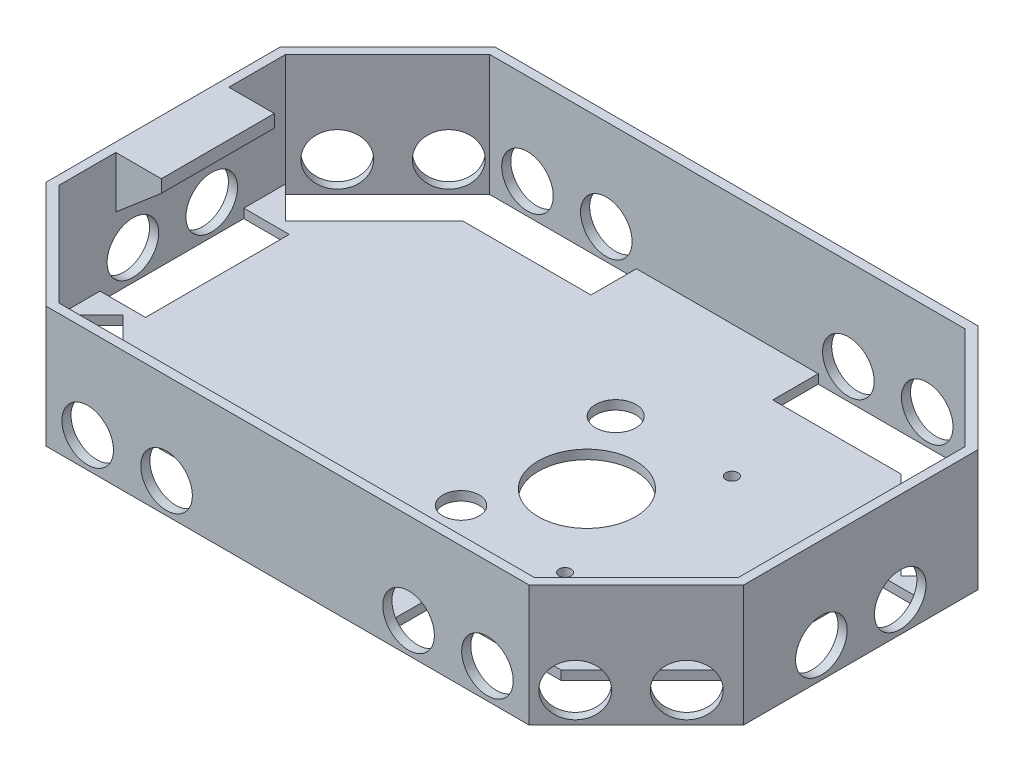
from build123d import *

# Parameters (mm, degrees)
SKETCH2_W               = 230
SKETCH2_H               = 148
BOSS_EXTRUDE1_DEPTH     = 40
CUT_EXTRUDE2_DEPTH      = 126
SHELL2_T                = -3
SKETCH6_R               = 16
SKETCH6_R_2             = 6
SKETCH6_R_3             = 2
SKETCH6_R_4             = 6.65813103
SKETCH6_R_5             = 2.01097319
CUT_EXTRUDE3_DEPTH      = 126
SKETCH8_W               = 15
SKETCH8_H               = 47.399828673
CUT_EXTRUDE4_DEPTH      = 10
SKETCH12_R              = 8.5
CUT_EXTRUDE7_DEPTH      = 4
CUT_EXTRUDE7_DEPTH_BACK = 13
SKETCH13_R              = 8.5
CUT_EXTRUDE8_DEPTH      = 10
SKETCH14_R              = 8.5
CUT_EXTRUDE9_DEPTH      = 10
SKETCH15_R              = 8.5
CUT_EXTRUDE10_DEPTH     = 10
SKETCH16_R              = 8.5
CUT_EXTRUDE11_DEPTH     = 10
SKETCH17_R              = 8.5
CUT_EXTRUDE12_DEPTH     = 10
SKETCH18_R              = 8.5
CUT_EXTRUDE13_DEPTH     = 10
SKETCH19_R              = 8.5
CUT_EXTRUDE14_DEPTH     = 10
SKETCH23_W              = 37.252555384
SKETCH23_H              = 4.191255607
BOSS_EXTRUDE2_DEPTH     = 15
BOSS_EXTRUDE3_DEPTH     = 37.252555


with BuildPart() as part:
    # Sketch2 → Boss-Extrude1 (new body)
    with BuildSketch(Plane(origin=(0, 0, 0), x_dir=(1, 0, 0), z_dir=(0, 1, 0))):
        Rectangle(SKETCH2_W, SKETCH2_H)
    extrude(amount=BOSS_EXTRUDE1_DEPTH)

    # Sketch4 → Cut-Extrude2 (cut)
    with BuildSketch(Plane(origin=(0, 40, 0), x_dir=(1, 0, 0), z_dir=(0, 1, 0))):
        Polygon((-79.644660941, 74), (-115, 38.644660941), (-115, 74), align=None)
        Polygon((115, 74), (79.644660941, 74), (115, 38.644660941), align=None)
        Polygon((115, -38.644660941), (115, -74), (79.644660941, -74), align=None)
        Polygon((-115, -74), (-79.644660941, -74), (-115, -38.644660941), align=None)
    extrude(amount=-CUT_EXTRUDE2_DEPTH, mode=Mode.SUBTRACT)

    # Shell2
    shell2_openings = [part.faces().sort_by_distance(p)[0] for p in [
        (0, 40, 0),
    ]]
    offset(amount=SHELL2_T, openings=shell2_openings, kind=Kind.INTERSECTION)

    # Sketch6 → Cut-Extrude3 (cut)
    with BuildSketch(Plane.XZ):
        with Locations((24.697986577, 0)):
            Circle(SKETCH6_R)
        with Locations((8.697986577, 25.5)):
            Circle(SKETCH6_R_2)
        with Locations((45, 27.5)):
            Circle(SKETCH6_R_3)
        with Locations((8.697986577, -25.5)):
            Circle(SKETCH6_R_4)
        with Locations((45, -27.5)):
            Circle(SKETCH6_R_5)
    extrude(amount=-CUT_EXTRUDE3_DEPTH, mode=Mode.SUBTRACT)

    # Sketch8 → Cut-Extrude4 (cut)
    with BuildSketch(Plane(origin=(0, 3, 0), x_dir=(1, 0, 0), z_dir=(0, 1, 0))):
        Polygon((-75.93928893, 71), (-29.973726036, 71), (-29.973726036, 56), (-72.188816818, 56), (-101.393398282, 26.795418536), (-112, 37.402020254), (-78.402020254, 71), align=None)
        with Locations((104.5, -0.132528068)):
            Rectangle(SKETCH8_W, SKETCH8_H)
        with Locations((-104.5, -0.132528068)):
            Rectangle(SKETCH8_W, SKETCH8_H)
        Polygon((101.393398282, 26.795418536), (72.188816818, 56), (29.973726036, 56), (29.973726036, 71), (75.93928893, 71), (78.402020254, 71), (112, 37.402020254), align=None)
        Polygon((112, -37.402020254), (101.393398282, -26.795418536), (72.188816818, -56), (29.973726036, -56), (29.973726036, -71), (75.93928893, -71), (78.402020254, -71), align=None)
        Polygon((-101.393398282, -26.795418536), (-72.188816818, -56), (-29.973726036, -56), (-29.973726036, -71), (-75.93928893, -71), (-78.402020254, -71), (-112, -37.402020254), align=None)
    extrude(amount=-CUT_EXTRUDE4_DEPTH, mode=Mode.SUBTRACT)

    # Sketch12 → Cut-Extrude7 (cut, two sides)
    with BuildSketch(Plane.XY.offset(74)) as cut_extrude7_sk:
        with Locations((-65.902020254, 10)):
            Circle(SKETCH12_R)
        with Locations((-39.902020254, 10)):
            Circle(SKETCH12_R)
        with Locations((39.902020254, 10)):
            Circle(SKETCH12_R)
        with Locations((65.902020254, 10)):
            Circle(SKETCH12_R)
    extrude(amount=CUT_EXTRUDE7_DEPTH, mode=Mode.SUBTRACT)
    extrude(cut_extrude7_sk.sketch, amount=-CUT_EXTRUDE7_DEPTH_BACK, mode=Mode.SUBTRACT)

    # Sketch13 → Cut-Extrude8 (cut)
    with BuildSketch(Plane(origin=(0, 0, -74), x_dir=(-1, 0, 0), z_dir=(0, 0, -1))):
        with Locations((-39.902020254, 10)):
            Circle(SKETCH13_R)
        with Locations((-65.902020254, 10)):
            Circle(SKETCH13_R)
        with Locations((39.902020254, 10)):
            Circle(SKETCH13_R)
        with Locations((65.902020254, 10)):
            Circle(SKETCH13_R)
    extrude(amount=-CUT_EXTRUDE8_DEPTH, mode=Mode.SUBTRACT)

    # Sketch14 → Cut-Extrude9 (cut)
    with BuildSketch(Plane.ZY.offset(115)):
        with Locations((12.997979746, 10)):
            Circle(SKETCH14_R)
        with Locations((-13.002020254, 10)):
            Circle(SKETCH14_R)
    extrude(amount=-CUT_EXTRUDE9_DEPTH, mode=Mode.SUBTRACT)

    # Sketch15 → Cut-Extrude10 (cut)
    with BuildSketch(Plane(origin=(-76.82233047, 0, -76.82233047), x_dir=(-0.707106781, 0, 0.707106781), z_dir=(-0.707106781, 0, -0.707106781))):
        with Locations((14.734018716, 10)):
            Circle(SKETCH15_R)
        with Locations((40.734018716, 10)):
            Circle(SKETCH15_R)
    extrude(amount=-CUT_EXTRUDE10_DEPTH, mode=Mode.SUBTRACT)

    # Sketch16 → Cut-Extrude11 (cut)
    with BuildSketch(Plane(origin=(-76.82233047, 0, 76.82233047), x_dir=(0.707106781, 0, 0.707106781), z_dir=(-0.707106781, 0, 0.707106781))):
        with Locations((-40.734018716, 10)):
            Circle(SKETCH16_R)
        with Locations((-14.734018716, 10)):
            Circle(SKETCH16_R)
    extrude(amount=-CUT_EXTRUDE11_DEPTH, mode=Mode.SUBTRACT)

    # Sketch17 → Cut-Extrude12 (cut)
    with BuildSketch(Plane(origin=(115, 0, 0), x_dir=(0, 0, -1), z_dir=(1, 0, 0))):
        with Locations((13.002020254, 10)):
            Circle(SKETCH17_R)
        with Locations((-12.997979746, 10)):
            Circle(SKETCH17_R)
    extrude(amount=-CUT_EXTRUDE12_DEPTH, mode=Mode.SUBTRACT)

    # Sketch18 → Cut-Extrude13 (cut)
    with BuildSketch(Plane(origin=(76.82233047, 0, 76.82233047), x_dir=(0.707106781, 0, -0.707106781), z_dir=(0.707106781, 0, 0.707106781))):
        with Locations((40.734018716, 10)):
            Circle(SKETCH18_R)
        with Locations((14.734018716, 10)):
            Circle(SKETCH18_R)
    extrude(amount=-CUT_EXTRUDE13_DEPTH, mode=Mode.SUBTRACT)

    # Sketch19 → Cut-Extrude14 (cut)
    with BuildSketch(Plane(origin=(76.82233047, 0, -76.82233047), x_dir=(-0.707106781, 0, -0.707106781), z_dir=(0.707106781, 0, -0.707106781))):
        with Locations((-40.734018716, 10)):
            Circle(SKETCH19_R)
        with Locations((-14.734018716, 10)):
            Circle(SKETCH19_R)
    extrude(amount=-CUT_EXTRUDE14_DEPTH, mode=Mode.SUBTRACT)

    # Sketch23 → Boss-Extrude2 (add)
    with BuildSketch(Plane(origin=(-112, 0, 0), x_dir=(0, 0, -1), z_dir=(1, 0, 0))):
        with Locations((0, 37.904372197)):
            Rectangle(SKETCH23_W, SKETCH23_H)
    extrude(amount=BOSS_EXTRUDE2_DEPTH)

    # Sketch26 → Boss-Extrude3 (add)
    with BuildSketch(Plane.XY.offset(18.626277692)):
        Polygon((-112.232432426, 35.808744393), (-112.232432426, 22.816581324), (-97, 35.808744393), align=None)
    extrude(amount=-BOSS_EXTRUDE3_DEPTH)


solid = part.part
